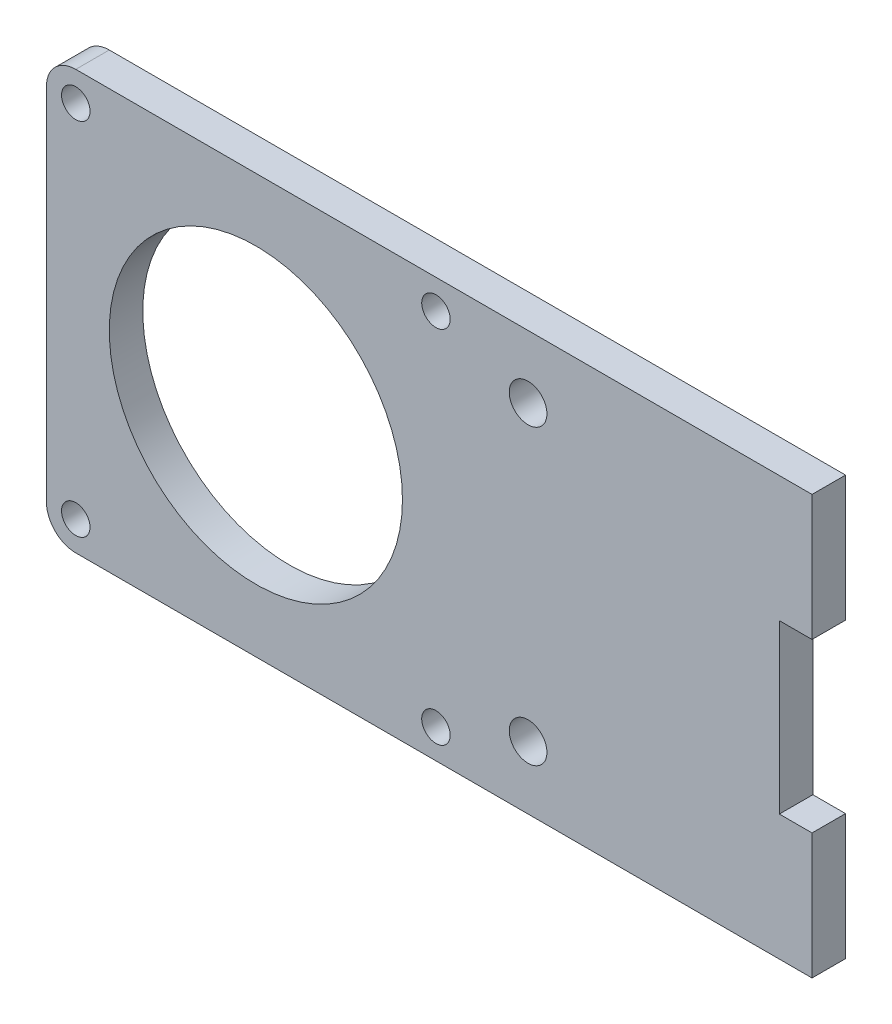
from build123d import *

# Parameters (mm, degrees)
SKETCH_1_R         = 17.5
EXTRUDE_1_DEPTH    = 4
HOLE_WIZARD_M3_1_D = 3.4
HOLE_WIZARD_M4_1_D = 4.5
FILLET_2_R         = 3.5


with BuildPart() as part:
    # ｽｹｯﾁ1 → ﾎﾞｽ - 押し出し1 (new body)
    with BuildSketch(Plane(origin=(0, 0, 0), x_dir=(0, 1, 0), z_dir=(0, 0, 1))):
        Polygon((0, 87.5), (0, -3.9), (15, -3.9), (15, 0), (35, 0), (35, -3.9), (50, -3.9), (50, 87.5), align=None)
        with Locations((25, 62.5)):
            Circle(SKETCH_1_R, mode=Mode.SUBTRACT)
    extrude(amount=EXTRUDE_1_DEPTH)

    # M3 すきま穴1 (through all)
    with Locations(Plane.XY.offset(4)):
        with Locations((-84, 3.5), (-84, 46.5), (-41, 46.5), (-41, 3.5)):
            Hole(HOLE_WIZARD_M3_1_D / 2)

    # M4 すきま穴1 (through all)
    with Locations(Plane.XY.offset(4)):
        with Locations((-30, 42.5), (-30, 7.5)):
            Hole(HOLE_WIZARD_M4_1_D / 2)

    # ﾌｨﾚｯﾄ2
    fillet_2_edges = [part.edges().sort_by_distance(p)[0] for p in [
        (-87.5, 50, 2),
        (-87.5, 0, 2),
    ]]
    fillet(fillet_2_edges, radius=FILLET_2_R)


solid = part.part
